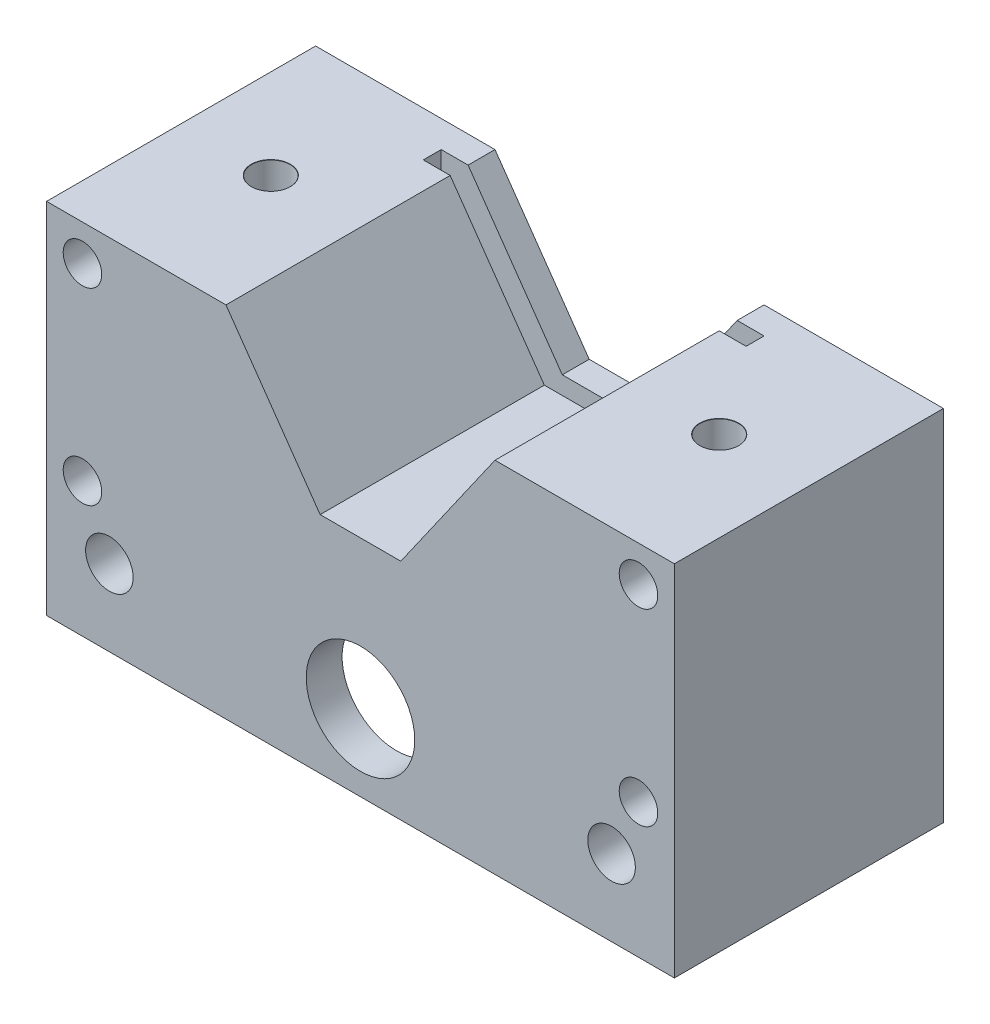
from build123d import *

# Parameters (mm, degrees)
AUFSATZ_LINEAR_AUSTRAGEN1_DEPTH            = 30
DURCHGANGSLOCH_F_R_M51_D                   = 5.3
DURCHGANGSLOCH_F_R_M43_REACH               = 68.321
DURCHGANGSLOCH_F_R_M43_BORE_R              = 2.15
DURCHGANGSLOCH_F_R_M41_D                   = 4.3
DURCHGANGSLOCH_F_R_M41_CSINK_D             = 4.35
DURCHGANGSLOCH_F_R_M41_CSINK_ANGLE         = 90
SKIZZE21_W                                 = 40
SKIZZE21_H                                 = 20
SCHNITT_LINEAR_AUSTRAGEN5_DEPTH            = 22
SKIZZE22_R                                 = 6.05
SCHNITT_LINEAR_AUSTRAGEN6_DEPTH            = 4.5
F_6_2_6_2_DURCHMESSER_BOHRUNG1_D           = 6.2
F_6_2_6_2_DURCHMESSER_BOHRUNG1_CSINK_D     = 6.25
F_6_2_6_2_DURCHMESSER_BOHRUNG1_CSINK_ANGLE = 90
SKIZZE25_R                                 = 6.05
SCHNITT_LINEAR_AUSTRAGEN7_DEPTH            = 4
DURCHGANGSLOCH_F_R_M42_D                   = 4.3
DURCHGANGSLOCH_F_R_M42_DEPTH               = 9
DURCHGANGSLOCH_F_R_M42_CSINK_D             = 4.35
DURCHGANGSLOCH_F_R_M42_CSINK_ANGLE         = 90
DURCHGANGSLOCH_F_R_M42_TIP                 = 1.291850331
SKIZZE30_W                                 = 36
SKIZZE30_H                                 = 2
SCHNITT_LINEAR_AUSTRAGEN8_DEPTH            = 23


with BuildPart() as part:
    # Skizze1 → Aufsatz-Linear austragen1 (new body)
    with BuildSketch(Plane.XY):
        Polygon((26.428839574, -31.372693626), (-43.571160426, -31.372693626), (-43.571160426, 8.627306374), (-23.571160426, 8.627306374), (-13.068047352, -6.372693626), (-4.074273499, -6.372693626), (6.428839574, 8.627306374), (26.428839574, 8.627306374), align=None)
    extrude(amount=AUFSATZ_LINEAR_AUSTRAGEN1_DEPTH)

    # Durchgangsloch für M51 (through all)
    with Locations(Plane.XY.offset(30)):
        with Locations((-36.571160426, -22.872693626), (19.428839574, -22.872693626)):
            Hole(DURCHGANGSLOCH_F_R_M51_D / 2)

    # Durchgangsloch für M43 bore → Durchgangsloch für M43 (cut, up to next)
    with BuildSketch(Plane(origin=(0, -31.372693626, 0), x_dir=(-1, 0, 0), z_dir=(0, -1, 0)), mode=Mode.PRIVATE) as durchgangsloch_f_r_m43_sk1:
        with Locations((36.571160426, -15)):
            Circle(DURCHGANGSLOCH_F_R_M43_BORE_R)
    durchgangsloch_f_r_m43_tool1 = extrude(durchgangsloch_f_r_m43_sk1.sketch, amount=-DURCHGANGSLOCH_F_R_M43_REACH, mode=Mode.PRIVATE) & part.part
    # Durchgangsloch für M43 bore → Durchgangsloch für M43 (cut, up to next)
    with BuildSketch(Plane(origin=(0, -31.372693626, 0), x_dir=(-1, 0, 0), z_dir=(0, -1, 0)), mode=Mode.PRIVATE) as durchgangsloch_f_r_m43_sk2:
        with Locations((-19.428839574, -15)):
            Circle(DURCHGANGSLOCH_F_R_M43_BORE_R)
    durchgangsloch_f_r_m43_tool2 = extrude(durchgangsloch_f_r_m43_sk2.sketch, amount=-DURCHGANGSLOCH_F_R_M43_REACH, mode=Mode.PRIVATE) & part.part
    add(durchgangsloch_f_r_m43_tool1.solids().sort_by_distance((-36.57116, -31.372694, 15))[0], mode=Mode.SUBTRACT)
    add(durchgangsloch_f_r_m43_tool2.solids().sort_by_distance((19.42884, -31.372694, 15))[0], mode=Mode.SUBTRACT)

    # Durchgangsloch für M41 (through all)
    with Locations(Plane(origin=(0, 0, 0), x_dir=(-1, 0, 0), z_dir=(0, 0, -1))):
        with Locations((-22.428839574, 4.627306374), (-22.428839574, -16.372693626), (39.571160426, -16.372693626), (39.571160426, 4.627306374)):
            CounterSinkHole(DURCHGANGSLOCH_F_R_M41_D / 2, DURCHGANGSLOCH_F_R_M41_CSINK_D / 2, counter_sink_angle=DURCHGANGSLOCH_F_R_M41_CSINK_ANGLE)

    # Skizze21 → Schnitt-Linear austragen5 (cut)
    with BuildSketch(Plane.XZ.offset(31.372693626)):
        with Locations((-8.571160426, 16)):
            Rectangle(SKIZZE21_W, SKIZZE21_H)
    extrude(amount=-SCHNITT_LINEAR_AUSTRAGEN5_DEPTH, mode=Mode.SUBTRACT)

    # Skizze22 → Schnitt-Linear austragen6 (cut)
    with BuildSketch(Plane(origin=(0, 0, 0), x_dir=(-1, 0, 0), z_dir=(0, 0, -1))):
        with Locations((8.571160426, -22.872693626)):
            Circle(SKIZZE22_R)
    extrude(amount=-SCHNITT_LINEAR_AUSTRAGEN6_DEPTH, mode=Mode.SUBTRACT)

    # Ø6.2 (6.2) Durchmesser Bohrung1 (through all)
    with Locations(Plane(origin=(0, 0, 4.5), x_dir=(-1, 0, 0), z_dir=(0, 0, -1))):
        with Locations((8.571160426, -22.872693626)):
            CounterSinkHole(F_6_2_6_2_DURCHMESSER_BOHRUNG1_D / 2, F_6_2_6_2_DURCHMESSER_BOHRUNG1_CSINK_D / 2, counter_sink_angle=F_6_2_6_2_DURCHMESSER_BOHRUNG1_CSINK_ANGLE)

    # Skizze25 → Schnitt-Linear austragen7 (cut)
    with BuildSketch(Plane.XY.offset(30)):
        with Locations(Location((-8.571160426, -22.872693626, 0), (0, 0, 180))):
            Circle(SKIZZE25_R)
    extrude(amount=-SCHNITT_LINEAR_AUSTRAGEN7_DEPTH, mode=Mode.SUBTRACT)

    # Durchgangsloch für M42
    with Locations(Plane(origin=(0, 8.627306374, 0), x_dir=(1, 0, 0), z_dir=(0, 1, 0))):
        with Locations((-33.571160426, -15), (16.428839574, -15)):
            CounterSinkHole(DURCHGANGSLOCH_F_R_M42_D / 2, DURCHGANGSLOCH_F_R_M42_CSINK_D / 2, depth=DURCHGANGSLOCH_F_R_M42_DEPTH, counter_sink_angle=DURCHGANGSLOCH_F_R_M42_CSINK_ANGLE)
            with Locations((0, 0, -(DURCHGANGSLOCH_F_R_M42_DEPTH + DURCHGANGSLOCH_F_R_M42_TIP / 2))):  # 118° drill point
                Cone(0, DURCHGANGSLOCH_F_R_M42_D / 2, DURCHGANGSLOCH_F_R_M42_TIP, mode=Mode.SUBTRACT)

    # Skizze30 → Schnitt-Linear austragen8 (cut)
    with BuildSketch(Plane(origin=(0, 8.627306374, 0), x_dir=(1, 0, 0), z_dir=(0, 1, 0))):
        with Locations((-8.571160426, -4)):
            Rectangle(SKIZZE30_W, SKIZZE30_H)
    extrude(amount=-SCHNITT_LINEAR_AUSTRAGEN8_DEPTH, mode=Mode.SUBTRACT)


solid = part.part
